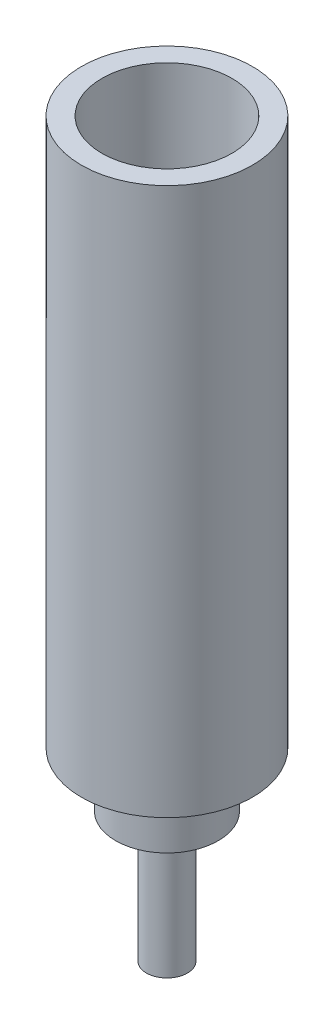
from build123d import *


with BuildPart() as part:
    # Esboço2 → Revolução1 (revolve)
    with BuildSketch(Plane.XY):
        Polygon((-12.5, 107), (-12.5, 27), (-7.5, 27), (-7.5, 19), (-3, 19), (-3, 0), (0, 0), (0, 32), (-9.5, 32), (-9.5, 107), align=None)
    revolve(axis=Axis((0, 98.34997688, 0), (0, -1, 0)))


solid = part.part
